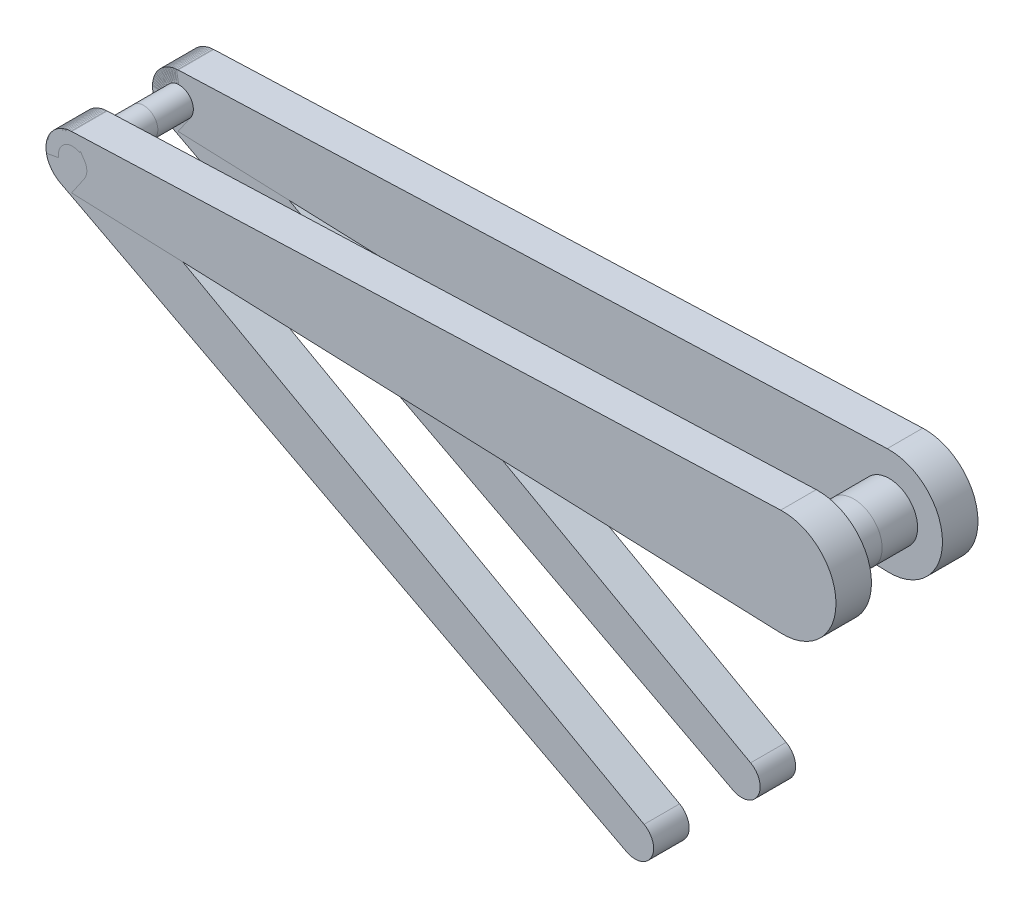
from build123d import *

# Parameters (mm, degrees)
SKETCH1_R           = 15
SKETCH1_R_2         = 7.5
BOSS_EXTRUDE1_DEPTH = 10
SKETCH1_3_R         = 7.5
SKETCH1_3_R_2       = 5.203025773
BOSS_EXTRUDE2_DEPTH = 10
SKETCH2_R           = 8
BOSS_EXTRUDE3_DEPTH = 10
SKETCH3_R           = 4
BOSS_EXTRUDE4_DEPTH = 10
SKETCH4_R           = 4
CUT_EXTRUDE1_DEPTH  = 70


with BuildPart() as part:
    # Sketch1 → Boss-Extrude1 (new body)
    with BuildSketch(Plane.XY):
        with BuildLine():
            Line((-0.5625, 14.989449415), (-200.28125, 7.494724707))
            ThreePointArc((-200.28125, 7.494724707), (-198.25423221, 7.293990322), (-196.355985213, 6.555238839))
            Line((-196.355985213, 6.555238839), (-168.967549637, -8.669814997))
            Line((-168.967549637, -8.669814997), (-0.5625, -14.989449415))
            ThreePointArc((-0.5625, -14.989449415), (-15, 0), (-0.5625, 14.989449415))
        make_face()
        Circle(SKETCH1_R)
        with Locations((-200, 0)):
            Circle(SKETCH1_R_2)
        with BuildLine():
            Line((-168.967549637, -8.669814997), (-196.355985213, 6.555238839))
            ThreePointArc((-196.355985213, 6.555238839), (-193.535477168, 3.802623377), (-192.5, 0))
            ThreePointArc((-192.5, 0), (-194.797086153, -5.401822609), (-200.28125, -7.494724707))
            Line((-200.28125, -7.494724707), (-168.967549637, -8.669814997))
        make_face()
    extrude(amount=BOSS_EXTRUDE1_DEPTH)

    # Sketch2 → Boss-Extrude3 (add)
    with BuildSketch(Plane(origin=(0, 0, 0), x_dir=(-1, 0, 0), z_dir=(0, 0, -1))):
        with Locations(Location((0, 0, 0), (0, 0, 180))):
            Circle(SKETCH2_R)
    extrude(amount=BOSS_EXTRUDE3_DEPTH)

    # Sketch4 → Cut-Extrude1 (cut)
    with BuildSketch(Plane(origin=(0, 0, -10), x_dir=(-1, 0, 0), z_dir=(0, 0, -1))):
        with Locations(Location((200, 0, 0), (0, 0, 180))):
            Circle(SKETCH4_R)
    extrude(amount=-CUT_EXTRUDE1_DEPTH, mode=Mode.SUBTRACT)


with BuildPart() as body_2:
    # Sketch1_3 → Boss-Extrude2 (new body)
    with BuildSketch(Plane.XY):
        with BuildLine():
            ThreePointArc((-200.28125, -7.494724707), (-201.925722688, -7.248557934), (-203.475539225, -6.646098637))
            Line((-203.475539225, -6.646098637), (-43.982159648, -90.052248175))
            ThreePointArc((-43.982159648, -90.052248175), (-46.150549785, -82.971855876), (-39.043063246, -80.893994958))
            Line((-39.043063246, -80.893994958), (-168.967549637, -8.669814997))
            Line((-168.967549637, -8.669814997), (-200.28125, -7.494724707))
        make_face()
        with Locations((-200, 0)):
            Circle(SKETCH1_3_R)
        with BuildLine():
            Line((-168.967549637, -8.669814997), (-196.355985213, 6.555238839))
            ThreePointArc((-196.355985213, 6.555238839), (-193.535477168, 3.802623377), (-192.5, 0))
            ThreePointArc((-192.5, 0), (-194.797086153, -5.401822609), (-200.28125, -7.494724707))
            Line((-200.28125, -7.494724707), (-168.967549637, -8.669814997))
        make_face()
        with Locations((-41.571050293, -85.441605175)):
            Circle(SKETCH1_3_R_2)
    extrude(amount=BOSS_EXTRUDE2_DEPTH)

    # Sketch3 → Boss-Extrude4 (add)
    with BuildSketch(Plane(origin=(0, 0, 0), x_dir=(-1, 0, 0), z_dir=(0, 0, -1))):
        with Locations(Location((200, 0, 0), (0, 0, 180))):
            Circle(SKETCH3_R)
    extrude(amount=BOSS_EXTRUDE4_DEPTH)


with BuildPart() as body_3:
    # Mirror1: mirrored copy
    add(body_2.part.mirror(Plane(origin=(0, 0, -10), x_dir=(1, 0, 0), z_dir=(0, 0, -1))))


with BuildPart() as body_4:
    # Mirror1 2: mirrored copy
    add(part.part.mirror(Plane(origin=(0, 0, -10), x_dir=(1, 0, 0), z_dir=(0, 0, -1))))


solid = Compound([part.part, body_2.part, body_3.part, body_4.part])
